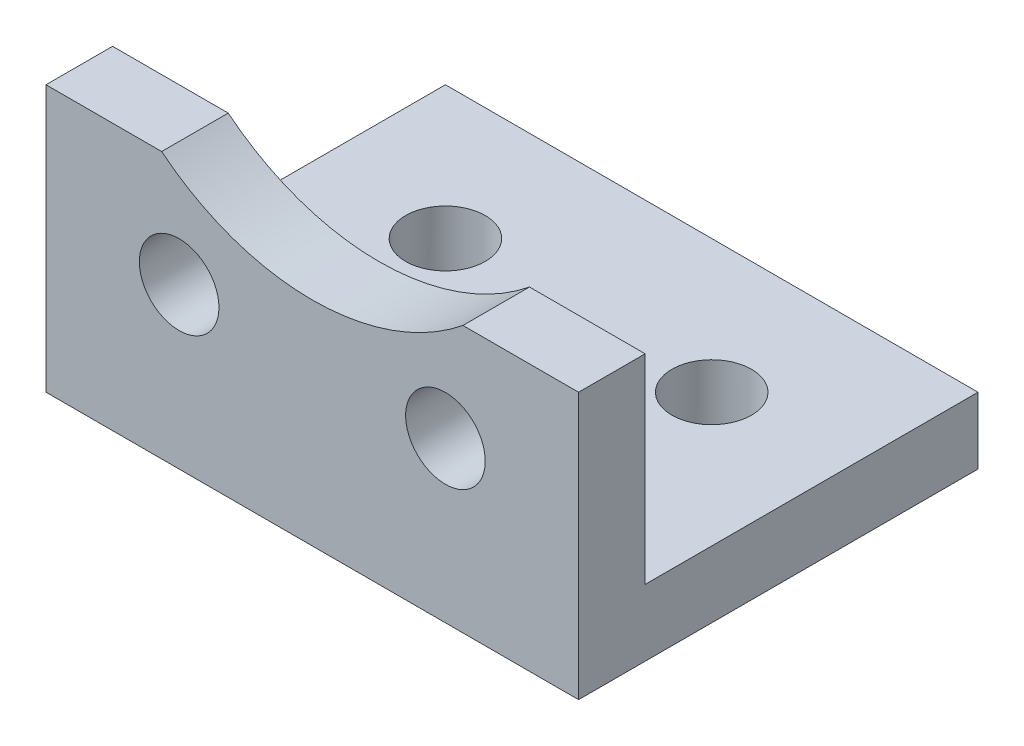
from build123d import *

# Parameters (mm, degrees)
EXTRUDE1_DEPTH                      = 12.7
EXTRUDE1_DEPTH_BACK                 = 12.7
F_6_CLEARANCE_HOLE1_D               = 3.7973
F_6_CLEARANCE_HOLE1_DEPTH           = 12.7
F_6_CLEARANCE_HOLE1_TIP             = 1.140824014
F_6_CLEARANCE_HOLE1_ON_FACE_2_D     = 3.7973
F_6_CLEARANCE_HOLE1_ON_FACE_2_DEPTH = 12.7
F_6_CLEARANCE_HOLE1_ON_FACE_2_TIP   = 1.140824014
SKETCH4_R                           = 11.43
CUT_EXTRUDE1_DEPTH                  = 24.970724332


with BuildPart() as part:
    # Sketch2 → Extrude1 (new, two sides: drawn at the far end of the back side and taken through both)
    with BuildSketch(Plane(origin=(0, 0, 0), x_dir=(0, 0, -1), z_dir=(1, 0, 0)).offset(-EXTRUDE1_DEPTH_BACK)):
        Polygon((0, 0), (0, 12.7), (3.175, 12.7), (3.175, 3.175), (19.05, 3.175), (19.05, 0), align=None)
    extrude(amount=EXTRUDE1_DEPTH + EXTRUDE1_DEPTH_BACK)

    # 6 Clearance Hole1
    with Locations(Plane(origin=(6.35, 7.62, -3.175), x_dir=(0, -1, 0), z_dir=(0, 0, -1))):
        with Locations((0, 0), (0, 12.7)):
            Hole(F_6_CLEARANCE_HOLE1_D / 2, depth=F_6_CLEARANCE_HOLE1_DEPTH)
            with Locations((0, 0, -(F_6_CLEARANCE_HOLE1_DEPTH + F_6_CLEARANCE_HOLE1_TIP / 2))):  # 118° drill point
                Cone(0, F_6_CLEARANCE_HOLE1_D / 2, F_6_CLEARANCE_HOLE1_TIP, mode=Mode.SUBTRACT)

    # 6 Clearance Hole1 on face 2
    with Locations(Plane(origin=(6.35, 3.175, -12.7), x_dir=(0, 0, 1), z_dir=(0, 1, 0))):
        with Locations((0, 0), (0, -12.7)):
            Hole(F_6_CLEARANCE_HOLE1_ON_FACE_2_D / 2, depth=F_6_CLEARANCE_HOLE1_ON_FACE_2_DEPTH)
            with Locations((0, 0, -(F_6_CLEARANCE_HOLE1_ON_FACE_2_DEPTH + F_6_CLEARANCE_HOLE1_ON_FACE_2_TIP / 2))):  # 118° drill point
                Cone(0, F_6_CLEARANCE_HOLE1_ON_FACE_2_D / 2, F_6_CLEARANCE_HOLE1_ON_FACE_2_TIP, mode=Mode.SUBTRACT)

    # Sketch4 → Cut-Extrude1 (cut, through all)
    with BuildSketch(Plane(origin=(0, 0, -3.175), x_dir=(-1, 0, 0), z_dir=(0, 0, -1))):
        with Locations((0, 21.59)):
            Circle(SKETCH4_R)
    extrude(amount=-CUT_EXTRUDE1_DEPTH, mode=Mode.SUBTRACT)


solid = part.part
